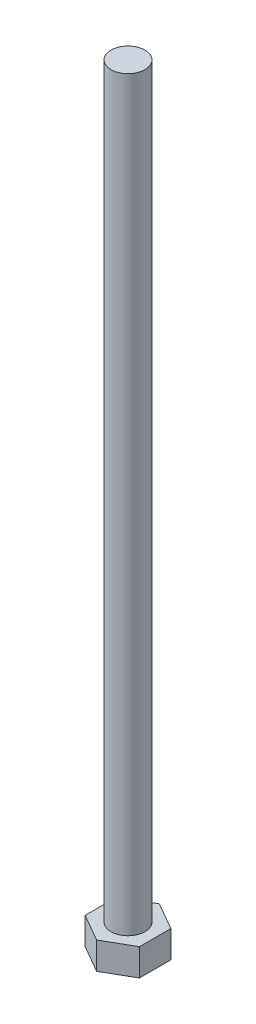
from build123d import *

# Parameters (mm, degrees)
EXTRUDE_1_DEPTH = 4
SKETCH_3_R      = 2.5
EXTRUDE_2_DEPTH = 110


with BuildPart() as part:
    # Эскиз2 → Бобышка-Вытянуть1 (new body)
    with BuildSketch(Plane(origin=(0, 0, 0), x_dir=(1, 0, 0), z_dir=(0, 1, 0))):
        Polygon((4, -2.309401077), (4, 2.309401077), (0, 4.618802154), (-4, 2.309401077), (-4, -2.309401077), (0, -4.618802154), align=None)
    extrude(amount=EXTRUDE_1_DEPTH)

    # Эскиз3 → Бобышка-Вытянуть2 (add)
    with BuildSketch(Plane(origin=(0, 4, 0), x_dir=(1, 0, 0), z_dir=(0, 1, 0))):
        Circle(SKETCH_3_R)
    extrude(amount=EXTRUDE_2_DEPTH)


solid = part.part
